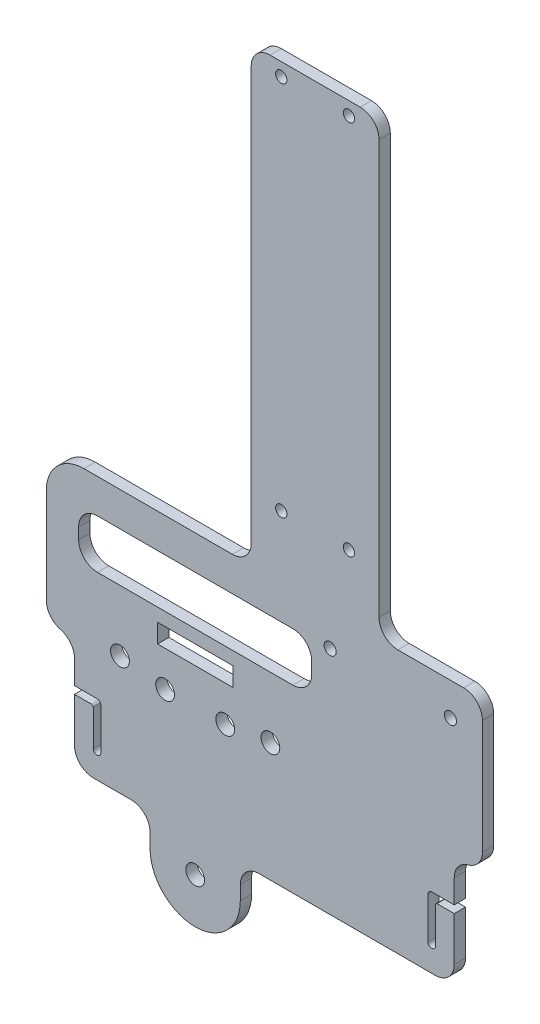
from build123d import *

# Parameters (mm, degrees)
SKETCH1_W           = 200
SKETCH1_H           = 300
SKETCH1_W_2         = 158.527362204
SKETCH1_H_2         = 20
BOSS_EXTRUDE1_DEPTH = 3
SKETCH2_R           = 2.5
CUT_EXTRUDE1_DEPTH  = 5
CUT_EXTRUDE3_DEPTH  = 10
CUT_EXTRUDE4_REACH  = 183.673
SKETCH5_W           = 62
SKETCH5_H           = 13
FILLET2_R           = 5
FILLET3_R           = 10
FILLET4_R           = 5
CUT_EXTRUDE6_REACH  = 183.673
SKETCH7_R           = 1.6
CUT_EXTRUDE7_REACH  = 183.673
SKETCH8_R           = 2.5
SKETCH8_W           = 20
SKETCH8_H           = 5
FILLET6_R           = 1
FILLET7_R           = 0.5
SKETCH9_R           = 1.5
CUT_EXTRUDE8_DEPTH  = 10
FILLET8_R           = 5


with BuildPart() as part:
    # Sketch1 → Boss-Extrude1 (new body)
    with BuildSketch(Plane.XY):
        Rectangle(SKETCH1_W, SKETCH1_H)
        with Locations((20.736318898, 160)):
            Rectangle(SKETCH1_W_2, SKETCH1_H_2)
    extrude(amount=BOSS_EXTRUDE1_DEPTH)

    # Sketch2 → Cut-Extrude1 (cut)
    with BuildSketch(Plane.XY.offset(3)):
        with Locations((-12.4, -28.75)):
            Circle(SKETCH2_R)
        with Locations((7.6, 11.65)):
            Circle(SKETCH2_R)
        with Locations((-32.4, 11.65)):
            Circle(SKETCH2_R)
        Polygon((-44.5, -3.25), (-44.5, -1.25), (-37.5, -1.25), (-37.5, -13.25), (-39.5, -13.25), (-39.5, -3.25), align=None)
        Polygon((51.5, -3.25), (56.5, -3.25), (56.5, -1.25), (49.5, -1.25), (49.5, -13.25), (51.5, -13.25), align=None)
        with BuildLine():
            Line((-44.5, -3.25), (-44.5, -1.25))
            ThreePointArc((-44.5, -1.25), (-45.5, -2.25), (-44.5, -3.25))
        make_face()
        with BuildLine():
            ThreePointArc((-37.5, -13.25), (-38.5, -14.25), (-39.5, -13.25))
            Line((-39.5, -13.25), (-37.5, -13.25))
        make_face()
        with BuildLine():
            ThreePointArc((51.5, -13.25), (50.5, -14.25), (49.5, -13.25))
            Line((49.5, -13.25), (51.5, -13.25))
        make_face()
        with BuildLine():
            ThreePointArc((56.5, -1.25), (57.5, -2.25), (56.5, -3.25))
            Line((56.5, -3.25), (56.5, -1.25))
        make_face()
    extrude(amount=-CUT_EXTRUDE1_DEPTH, mode=Mode.SUBTRACT)

    # Sketch4 → Cut-Extrude3 (cut)
    with BuildSketch(Plane.XY.offset(3)):
        with BuildLine():
            ThreePointArc((-44.5, -3.25), (-45.5, -2.25), (-44.5, -1.25))
            Line((-44.5, -1.25), (-44.5, 10))
            Line((-44.5, 10), (-52, 10))
            Line((-52, 10), (-52, 50))
            Line((-52, 50), (2.5, 50))
            Line((2.5, 50), (2.5, 170))
            Line((2.5, 170), (-58.527362204, 170))
            Line((-58.527362204, 170), (-58.527362204, 150))
            Line((-58.527362204, 150), (-100, 150))
            Line((-100, 150), (-100, -150))
            Line((-100, -150), (100, -150))
            Line((100, -150), (100, 170))
            Line((100, 170), (36.5, 170))
            Line((36.5, 170), (36.5, 50))
            Line((36.5, 50), (64, 50))
            Line((64, 50), (64, 10))
            Line((64, 10), (56.5, 10))
            Line((56.5, 10), (56.5, -1.25))
            ThreePointArc((56.5, -1.25), (57.5, -2.25), (56.5, -3.25))
            Line((56.5, -3.25), (56.5, -20))
            Line((56.5, -20), (-0.4, -20))
            Line((-0.4, -20), (-0.4, -28.75))
            ThreePointArc((-0.4, -28.75), (-12.4, -40.75), (-24.4, -28.75))
            Line((-24.4, -28.75), (-24.4, -20))
            Line((-24.4, -20), (-44.5, -20))
            Line((-44.5, -20), (-44.5, -3.25))
        make_face()
    extrude(amount=-CUT_EXTRUDE3_DEPTH, mode=Mode.SUBTRACT)

    # Sketch5 → Cut-Extrude4 (cut, up to next)
    with BuildSketch(Plane.XY.offset(3), mode=Mode.PRIVATE) as cut_extrude4_sk1:
        with Locations((-12.4, 34.409289568)):
            Rectangle(SKETCH5_W, SKETCH5_H)
    cut_extrude4_tool1 = extrude(cut_extrude4_sk1.sketch, amount=-CUT_EXTRUDE4_REACH, mode=Mode.PRIVATE) & part.part
    add(cut_extrude4_tool1.solids().sort_by_distance((-12.4, 34.40929, 3))[0], mode=Mode.SUBTRACT)

    # Fillet2
    fillet2_edges = [part.edges().sort_by_distance(p)[0] for p in [
        (-43.4, 40.909289568, 1.5),
        (18.6, 40.909289568, 1.5),
        (18.6, 27.909289568, 1.5),
        (-43.4, 27.909289568, 1.5),
    ]]
    fillet(fillet2_edges, radius=FILLET2_R)

    # Fillet3
    fillet3_edges = [part.edges().sort_by_distance(p)[0] for p in [
        (-52, 50, 1.5),
    ]]
    fillet(fillet3_edges, radius=FILLET3_R)

    # Fillet4
    fillet4_edges = [part.edges().sort_by_distance(p)[0] for p in [
        (-44.5, -20, 1.5),
        (-24.4, -20, 1.5),
        (-0.4, -20, 1.5),
        (56.5, 10, 1.5),
        (64, 50, 1.5),
        (2.5, 50, 1.5),
        (36.5, 50, 1.5),
        (56.5, -20, 1.5),
        (-44.5, 10, 1.5),
    ]]
    fillet(fillet4_edges, radius=FILLET4_R)

    # Sketch7 → Cut-Extrude6 (cut, up to next)
    with BuildSketch(Plane.XY.offset(3), mode=Mode.PRIVATE) as cut_extrude6_sk1:
        with Locations((55.5, 41.3)):
            Circle(SKETCH7_R)
    cut_extrude6_tool1 = extrude(cut_extrude6_sk1.sketch, amount=-CUT_EXTRUDE6_REACH, mode=Mode.PRIVATE) & part.part
    # Sketch7 → Cut-Extrude6 (cut, up to next)
    with BuildSketch(Plane.XY.offset(3), mode=Mode.PRIVATE) as cut_extrude6_sk2:
        with Locations((23.5, 41.3)):
            Circle(SKETCH7_R)
    cut_extrude6_tool2 = extrude(cut_extrude6_sk2.sketch, amount=-CUT_EXTRUDE6_REACH, mode=Mode.PRIVATE) & part.part
    add(cut_extrude6_tool1.solids().sort_by_distance((55.5, 41.3, 3))[0], mode=Mode.SUBTRACT)
    add(cut_extrude6_tool2.solids().sort_by_distance((23.5, 41.3, 3))[0], mode=Mode.SUBTRACT)

    # Sketch8 → Cut-Extrude7 (cut, up to next)
    with BuildSketch(Plane.XY.offset(3), mode=Mode.PRIVATE) as cut_extrude7_sk1:
        with Locations((-4.4, 9.909289568)):
            Circle(SKETCH8_R)
    cut_extrude7_tool1 = extrude(cut_extrude7_sk1.sketch, amount=-CUT_EXTRUDE7_REACH, mode=Mode.PRIVATE) & part.part
    # Sketch8 → Cut-Extrude7 (cut, up to next)
    with BuildSketch(Plane.XY.offset(3), mode=Mode.PRIVATE) as cut_extrude7_sk2:
        with Locations((-20.4, 9.909289568)):
            Circle(SKETCH8_R)
    cut_extrude7_tool2 = extrude(cut_extrude7_sk2.sketch, amount=-CUT_EXTRUDE7_REACH, mode=Mode.PRIVATE) & part.part
    # Sketch8 → Cut-Extrude7 (cut, up to next)
    with BuildSketch(Plane.XY.offset(3), mode=Mode.PRIVATE) as cut_extrude7_sk3:
        with Locations((-12.4, 21.909289568)):
            Rectangle(SKETCH8_W, SKETCH8_H)
    cut_extrude7_tool3 = extrude(cut_extrude7_sk3.sketch, amount=-CUT_EXTRUDE7_REACH, mode=Mode.PRIVATE) & part.part
    add(cut_extrude7_tool1.solids().sort_by_distance((-4.4, 9.90929, 3))[0], mode=Mode.SUBTRACT)
    add(cut_extrude7_tool2.solids().sort_by_distance((-20.4, 9.90929, 3))[0], mode=Mode.SUBTRACT)
    add(cut_extrude7_tool3.solids().sort_by_distance((-12.4, 21.90929, 3))[0], mode=Mode.SUBTRACT)

    # Fillet6
    fillet6_edges = [part.edges().sort_by_distance(p)[0] for p in [
        (-37.5, -1.25, 1.5),
        (49.5, -1.25, 1.5),
    ]]
    fillet(fillet6_edges, radius=FILLET6_R)

    # Fillet7
    fillet7_edges = [part.edges().sort_by_distance(p)[0] for p in [
        (-39.5, -3.25, 1.5),
        (51.5, -3.25, 1.5),
    ]]
    fillet(fillet7_edges, radius=FILLET7_R)

    # Sketch9 → Cut-Extrude8 (cut)
    with BuildSketch(Plane.XY.offset(3)):
        with Locations((10.5, 166.5)):
            Circle(SKETCH9_R)
        with Locations((10.5, 66.5)):
            Circle(SKETCH9_R)
        with Locations((28.5, 166.5)):
            Circle(SKETCH9_R)
        with Locations((28.5, 66.5)):
            Circle(SKETCH9_R)
    extrude(amount=-CUT_EXTRUDE8_DEPTH, mode=Mode.SUBTRACT)

    # Fillet8
    fillet8_edges = [part.edges().sort_by_distance(p)[0] for p in [
        (2.5, 170, 1.5),
        (36.5, 170, 1.5),
        (-52, 10, 1.5),
        (64, 10, 1.5),
    ]]
    fillet(fillet8_edges, radius=FILLET8_R)


solid = part.part
